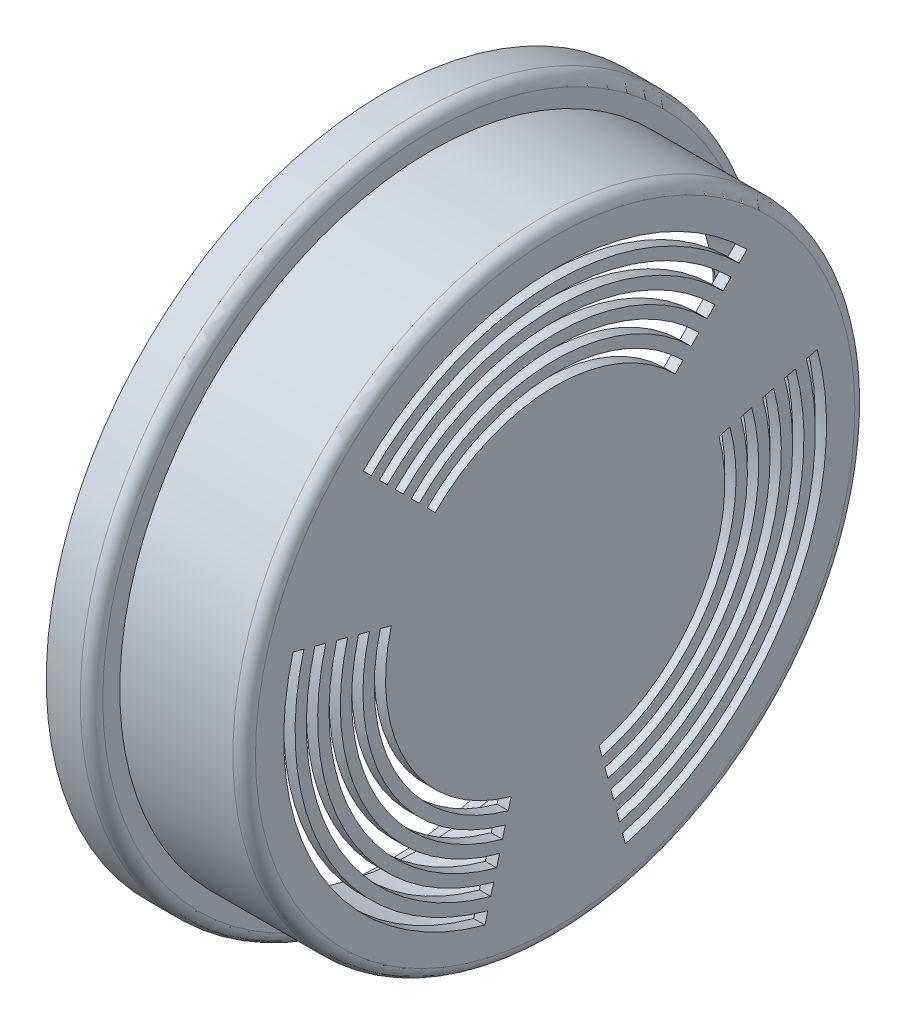
from build123d import *

# Parameters (mm, degrees)
FILLET1_R          = 2
FILLET2_R          = 2
CUT_EXTRUDE2_DEPTH = 2
CIRPATTERN1_COUNT  = 3


with BuildPart() as part:
    # Sketch1 → Revolve2 (revolve)
    with BuildSketch(Plane.XY):
        Polygon((-15, 60), (-7, 60), (-7, 55), (15, 55), (15, 0), (13, 0), (13, 53), (-9, 53), (-9, 58), (-15, 58), align=None)
    revolve(axis=Axis((-15, 0, 0), (1, 0, 0)))

    # Fillet1
    fillet1_edges = [part.edges().sort_by_distance(p)[0] for p in [
        (15, -55, 0),
        (-9, -58, 0),
    ]]
    fillet(fillet1_edges, radius=FILLET1_R)

    # Fillet2
    fillet2_edges = [part.edges().sort_by_distance(p)[0] for p in [
        (-7, -60, 0),
    ]]
    fillet(fillet2_edges, radius=FILLET2_R)

    # Sketch2 → Cut-Extrude2 (cut)
    with BuildSketch(Plane(origin=(15, 0, 0), x_dir=(0, 0, -1), z_dir=(1, 0, 0))):
        with BuildLine():
            Line((-22.627416998, 22.627416998), (-21.213203436, 21.213203436))
            ThreePointArc((-21.213203436, 21.213203436), (0, 30), (21.213203436, 21.213203436))
            Line((21.213203436, 21.213203436), (22.627416998, 22.627416998))
            ThreePointArc((22.627416998, 22.627416998), (0, 32), (-22.627416998, 22.627416998))
        make_face()
        with BuildLine():
            Line((-25.455844123, 25.455844123), (-24.04163056, 24.04163056))
            ThreePointArc((-24.04163056, 24.04163056), (0, 34), (24.04163056, 24.04163056))
            Line((24.04163056, 24.04163056), (25.455844123, 25.455844123))
            ThreePointArc((25.455844123, 25.455844123), (0, 36), (-25.455844123, 25.455844123))
        make_face()
        with BuildLine():
            Line((-28.284271247, 28.284271247), (-26.870057685, 26.870057685))
            ThreePointArc((-26.870057685, 26.870057685), (0, 38), (26.870057685, 26.870057685))
            Line((26.870057685, 26.870057685), (28.284271247, 28.284271247))
            ThreePointArc((28.284271247, 28.284271247), (0, 40), (-28.284271247, 28.284271247))
        make_face()
        with BuildLine():
            Line((-31.112698372, 31.112698372), (-29.69848481, 29.69848481))
            ThreePointArc((-29.69848481, 29.69848481), (0, 42), (29.69848481, 29.69848481))
            Line((29.69848481, 29.69848481), (31.112698372, 31.112698372))
            ThreePointArc((31.112698372, 31.112698372), (0, 44), (-31.112698372, 31.112698372))
        make_face()
        with BuildLine():
            Line((-33.941125497, 33.941125497), (-32.526911935, 32.526911935))
            ThreePointArc((-32.526911935, 32.526911935), (0, 46), (32.526911935, 32.526911935))
            Line((32.526911935, 32.526911935), (33.941125497, 33.941125497))
            ThreePointArc((33.941125497, 33.941125497), (0, 48), (-33.941125497, 33.941125497))
        make_face()
    cut_extrude2 = extrude(amount=-CUT_EXTRUDE2_DEPTH, mode=Mode.SUBTRACT)

    # CirPattern1: Cut-Extrude2 ×3 about axis
    cirpattern1_axis = Axis((0, 0, 0), (1, 0, 0))
    for i in range(1, CIRPATTERN1_COUNT):
        add(cut_extrude2.rotate(cirpattern1_axis, i * 360 / CIRPATTERN1_COUNT), mode=Mode.SUBTRACT)


solid = part.part
